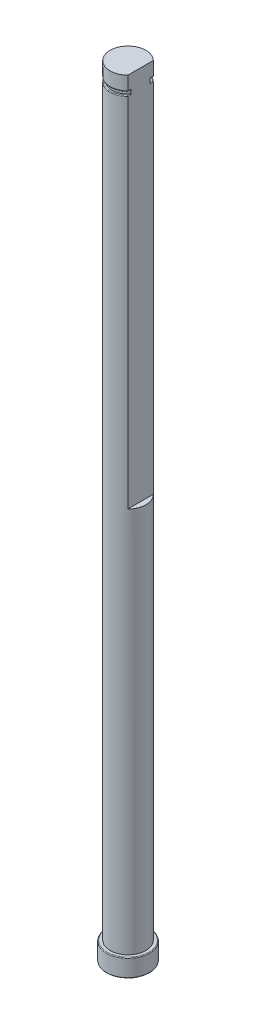
from build123d import *

# Parameters (mm, degrees)
SKETCH1_R           = 5
BOSS_EXTRUDE1_DEPTH = 217.89
CUT_EXTRUDE2_DEPTH  = 105
CUT_EXTRUDE3_START  = -5
CUT_EXTRUDE3_DEPTH  = 1
FILLET1_R           = 0.2
SKETCH5_R           = 6
SKETCH5_R_2         = 5
BOSS_EXTRUDE2_DEPTH = 5
FILLET2_R           = 0.2


with BuildPart() as part:
    # Sketch1 → Boss-Extrude1 (new body)
    with BuildSketch(Plane(origin=(0, 0, 0), x_dir=(1, 0, 0), z_dir=(0, 1, 0))):
        Circle(SKETCH1_R)
    extrude(amount=BOSS_EXTRUDE1_DEPTH)

    # Sketch3 → Cut-Extrude2 (cut)
    with BuildSketch(Plane(origin=(0, 217.89, 0), x_dir=(1, 0, 0), z_dir=(0, 1, 0))):
        Polygon((3.5, 37.712556906), (3.5, 3.570714214), (3.5, -3.570714214), (3.5, -37.712556906), (71.783685384, -37.712556906), (71.783685384, 37.712556906), align=None)
    extrude(amount=-CUT_EXTRUDE2_DEPTH, mode=Mode.SUBTRACT)

    # Sketch4 → Cut-Extrude3 (cut)
    with BuildSketch(Plane(origin=(0, 217.89, 0), x_dir=(1, 0, 0), z_dir=(0, 1, 0)).offset(CUT_EXTRUDE3_START)):
        with BuildLine():
            Line((3.5, 2.666458325), (3.5, 3.570714214))
            ThreePointArc((3.5, 3.570714214), (-5, 0), (3.5, -3.570714214))
            Line((3.5, -3.570714214), (3.5, -2.666458325))
            ThreePointArc((3.5, -2.666458325), (-4.4, 0), (3.5, 2.666458325))
        make_face()
    extrude(amount=CUT_EXTRUDE3_DEPTH, mode=Mode.SUBTRACT)

    # Fillet1
    fillet1_edges = [part.edges().sort_by_distance(p)[0] for p in [
        (3.5, 212.89, -3.11858627),
        (-5, 212.89, 0),
        (3.5, 212.89, 3.11858627),
        (3.5, 213.89, -3.11858627),
        (-5, 213.89, 0),
        (3.5, 213.89, 3.11858627),
    ]]
    fillet(fillet1_edges, radius=FILLET1_R)

    # Sketch5 → Boss-Extrude2 (add)
    with BuildSketch(Plane.XZ):
        Circle(SKETCH5_R)
        Circle(SKETCH5_R_2, mode=Mode.SUBTRACT)
    extrude(amount=-BOSS_EXTRUDE2_DEPTH)

    # Fillet2
    fillet2_edges = [part.edges().sort_by_distance(p)[0] for p in [
        (-6, 5, 0),
        (-6, 0, 0),
    ]]
    fillet(fillet2_edges, radius=FILLET2_R)


solid = part.part
